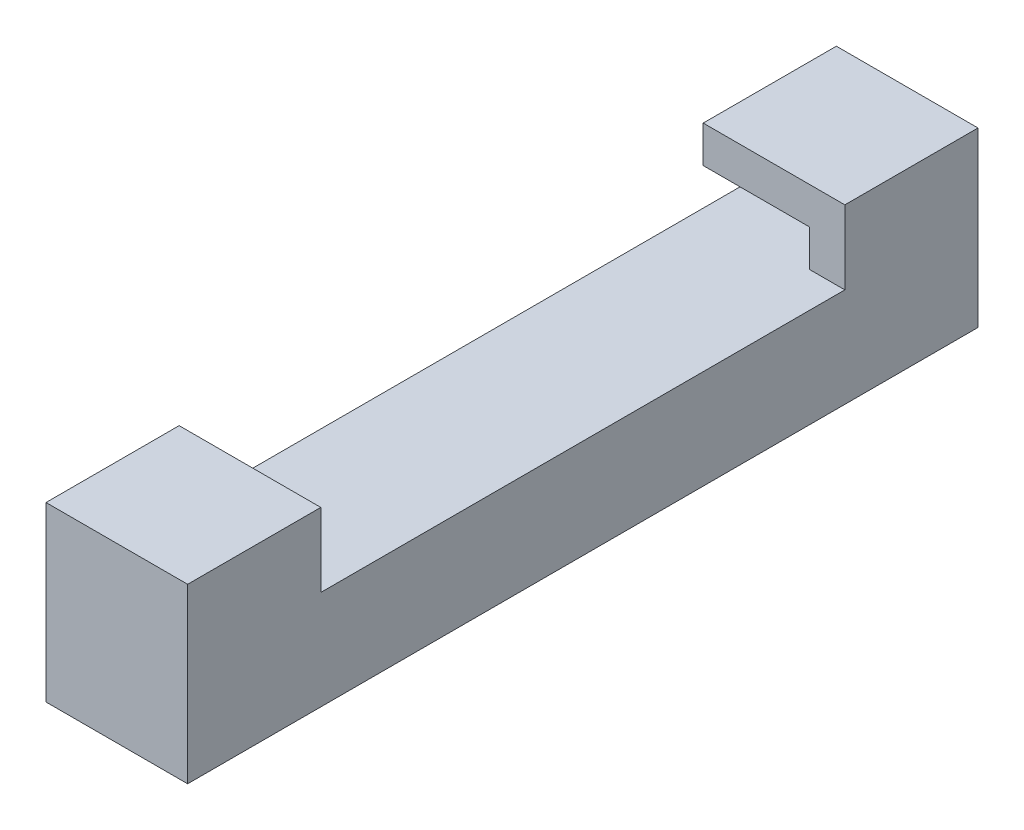
from build123d import *

# Parameters (mm, degrees)
BOSS_EXTRUDE1_DEPTH = 12.7
BOSS_EXTRUDE3_DEPTH = 12.7
CUT_EXTRUDE1_REACH  = 14.7
CUT_EXTRUDE2_REACH  = 14.7
SKETCH6_W           = 7.112
SKETCH6_H           = 3.302
BOSS_EXTRUDE4_DEPTH = 3.175
SKETCH7_W           = 7.112
SKETCH7_H           = 3.302
BOSS_EXTRUDE5_DEPTH = 3.175


with BuildPart() as part:
    # Sketch1 → Boss-Extrude1 (new body)
    with BuildSketch(Plane(origin=(0, 0, 0), x_dir=(0, 0, -1), z_dir=(1, 0, 0))):
        Polygon((0, 0), (80.01, 0), (80.01, 19.05), (71.12, 19.05), (71.12, 8.89), (8.89, 8.89), (8.89, 19.05), (0, 19.05), align=None)
    extrude(amount=BOSS_EXTRUDE1_DEPTH)

    # Sketch2 → Boss-Extrude3 (add)
    with BuildSketch(Plane.ZY):
        Polygon((-63.5, 12.192), (-70.612, 12.192), (-70.612, 8.89), (-74.93, 8.89), (-74.93, 15.494), (-63.5, 15.494), align=None)
        Polygon((-16.51, 12.192), (-9.398, 12.192), (-9.398, 8.89), (-5.08, 8.89), (-5.08, 15.494), (-16.51, 15.494), align=None)
    extrude(amount=-BOSS_EXTRUDE3_DEPTH)

    # Sketch4 → Cut-Extrude1 (cut, up to next)
    with BuildSketch(Plane.ZY, mode=Mode.PRIVATE) as cut_extrude1_sk1:
        Polygon((-71.12, 15.494), (-75.438, 15.494), (-75.438, 0), (-80.01, 0), (-80.01, 19.05), (-71.12, 19.05), align=None)
    cut_extrude1_tool1 = extrude(cut_extrude1_sk1.sketch, amount=-CUT_EXTRUDE1_REACH, mode=Mode.PRIVATE) & part.part
    add(cut_extrude1_tool1.solids().sort_by_distance((0, 10.686074, -77.05781))[0], mode=Mode.SUBTRACT)

    # Sketch5 → Cut-Extrude2 (cut, up to next)
    with BuildSketch(Plane.ZY, mode=Mode.PRIVATE) as cut_extrude2_sk1:
        Polygon((-8.89, 15.494), (-4.572, 15.494), (-4.572, 0), (0, 0), (0, 19.05), (-8.89, 19.05), align=None)
    cut_extrude2_tool1 = extrude(cut_extrude2_sk1.sketch, amount=-CUT_EXTRUDE2_REACH, mode=Mode.PRIVATE) & part.part
    add(cut_extrude2_tool1.solids().sort_by_distance((0, 10.686074, -2.95219))[0], mode=Mode.SUBTRACT)

    # Sketch6 → Boss-Extrude4 (add)
    with BuildSketch(Plane(origin=(12.7, 0, 0), x_dir=(0, 0, -1), z_dir=(1, 0, 0))):
        with Locations((12.954, 10.541)):
            Rectangle(SKETCH6_W, SKETCH6_H)
    extrude(amount=-BOSS_EXTRUDE4_DEPTH)

    # Sketch7 → Boss-Extrude5 (add)
    with BuildSketch(Plane(origin=(12.7, 0, 0), x_dir=(0, 0, -1), z_dir=(1, 0, 0))):
        with Locations((67.056, 10.541)):
            Rectangle(SKETCH7_W, SKETCH7_H)
    extrude(amount=-BOSS_EXTRUDE5_DEPTH)


solid = part.part
